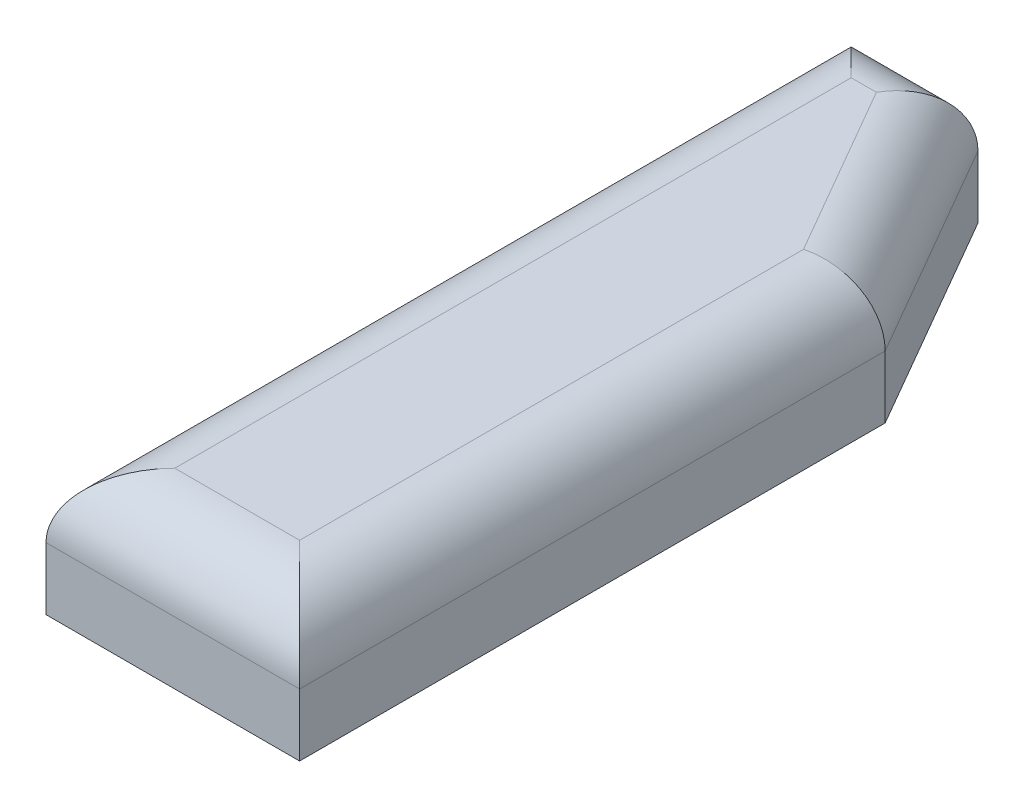
from build123d import *

# Parameters (mm, degrees)
BOSS_EXTRUDE1_DEPTH = 10
FILLET1_R           = 5.08


with BuildPart() as part:
    # Sketch1 → Boss-Extrude1 (new body)
    with BuildSketch(Plane(origin=(0, 0, 0), x_dir=(1, 0, 0), z_dir=(0, 1, 0))):
        Polygon((10, -31.75), (10, 14.429491924), (0, 31.75), (-10, 31.75), (-10, -31.75), align=None)
    extrude(amount=BOSS_EXTRUDE1_DEPTH)

    # Fillet1
    fillet1_edges = [part.edges().sort_by_distance(p)[0] for p in [
        (5, 10, -23.089745962),
        (-5, 10, -31.75),
        (-10, 10, 0),
        (0, 10, 31.75),
        (10, 10, 8.660254038),
    ]]
    fillet(fillet1_edges, radius=FILLET1_R)


solid = part.part
